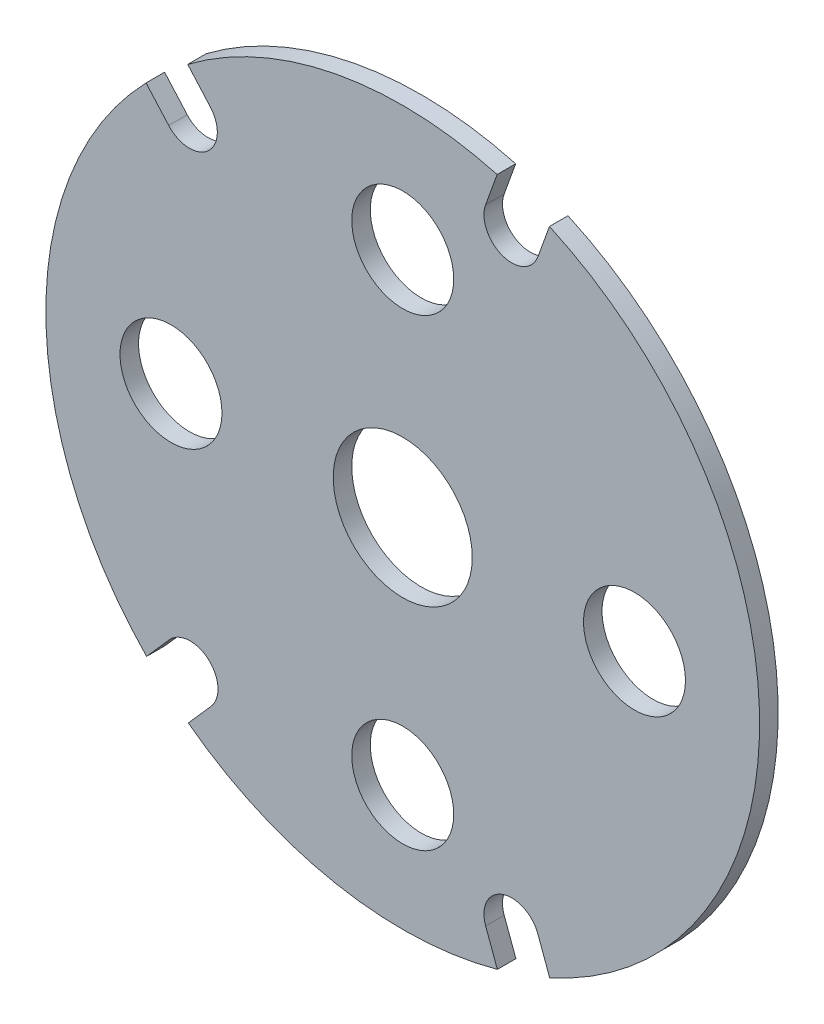
from build123d import *

# Parameters (mm, degrees)
MODEL_R             = 5.5
MODEL_R_2           = 7.5
BOSS_EXTRUDE1_DEPTH = 2


with BuildPart() as part:
    # Model → Boss-Extrude1 (new body)
    with BuildSketch(Plane.XY):
        with BuildLine():
            Line((8.947329511, -33.697448784), (10.207027791, -37.122319212))
            ThreePointArc((10.207027791, -37.122319212), (-7.201532375, -37.820469741), (-23.135313057, -30.773483549))
            Line((-23.135313057, -30.773483549), (-20.68154198, -27.990692072))
            ThreePointArc((-20.68154198, -27.990692072), (-20.947588277, -23.756401179), (-25.18187917, -24.022447477))
            Line((-25.18187917, -24.022447477), (-27.635650248, -26.805238954))
            ThreePointArc((-27.635650248, -26.805238954), (-38.49998136, -0.037885337), (-27.688351274, 26.750798188))
            Line((-27.688351274, 26.750798188), (-25.246259349, 23.992215172))
            ThreePointArc((-25.246259349, 23.992215172), (-21.011453059, 23.734502765), (-20.753740651, 27.969309055))
            Line((-20.753740651, 27.969309055), (-23.195832576, 30.727892071))
            ThreePointArc((-23.195832576, 30.727892071), (-7.250949904, 37.811026507), (10.183062279, 37.128900369))
            Line((10.183062279, 37.128900369), (8.940382065, 33.678361242))
            ThreePointArc((8.940382065, 33.678361242), (10.746378971, 29.839375176), (14.585365036, 31.645372081))
            Line((14.585365036, 31.645372081), (15.82804525, 35.095911209))
            ThreePointArc((15.82804525, 35.095911209), (38.499997976, 0.012482786), (15.85080009, -35.085640033))
            Line((15.85080009, -35.085640033), (14.578417591, -31.626283722))
            ThreePointArc((14.578417591, -31.626283722), (10.72729102, -29.846322213), (8.947329511, -33.697448784))
        make_face()
        with Locations((-25, 0)):
            Circle(MODEL_R, mode=Mode.SUBTRACT)
        with Locations((0, 25)):
            Circle(MODEL_R, mode=Mode.SUBTRACT)
        with Locations((0, -25)):
            Circle(MODEL_R, mode=Mode.SUBTRACT)
        with Locations((25, 0)):
            Circle(MODEL_R, mode=Mode.SUBTRACT)
        Circle(MODEL_R_2, mode=Mode.SUBTRACT)
    extrude(amount=BOSS_EXTRUDE1_DEPTH)


solid = part.part
